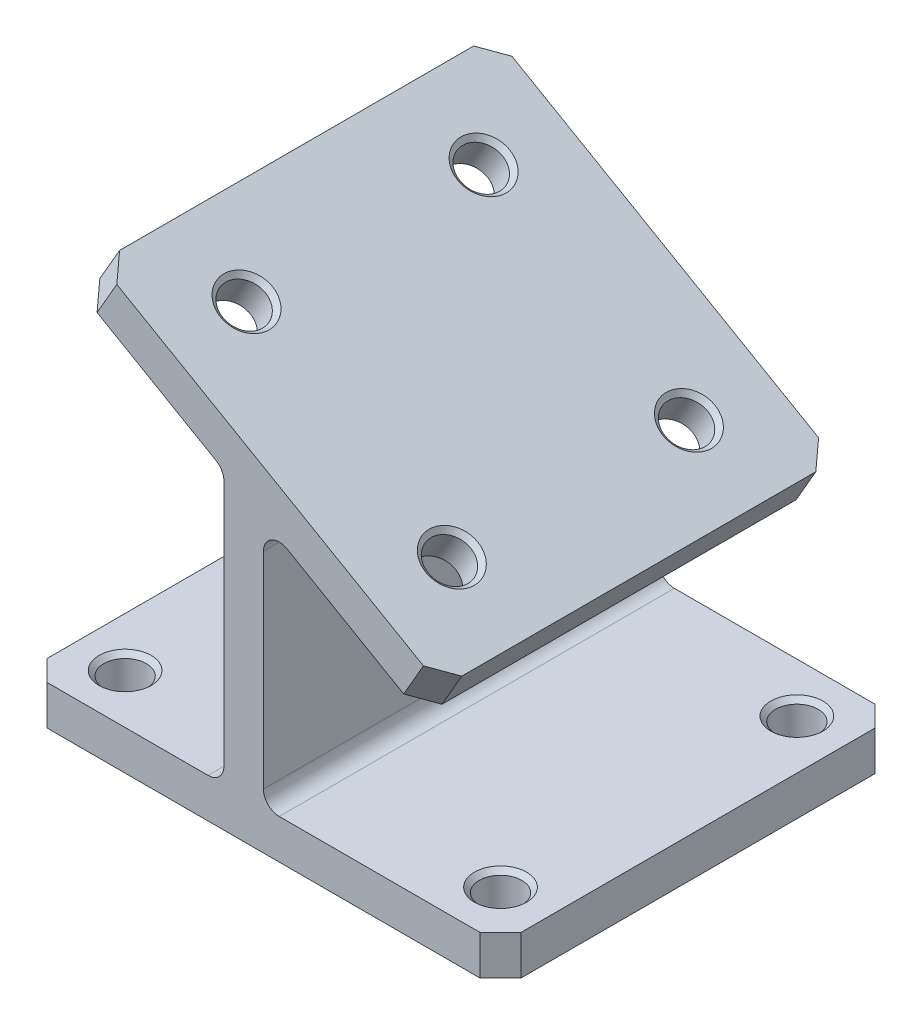
from build123d import *

# Parameters (mm, degrees)
BOSS_EXTRUDE1_DEPTH = 31.75
CHAMFER1_SIZE       = 3.302
CUT_EXTRUDE1_REACH  = 67.596
SKETCH2_R           = 3.429
CUT_EXTRUDE2_REACH  = 70.999
SKETCH3_R           = 3.429
CHAMFER2_SIZE       = 0.762


with BuildPart() as part:
    # Sketch1 → Boss-Extrude1 (new body, symmetric)
    with BuildSketch(Plane.XY):
        with BuildLine():
            Line((0, 2.54), (0, 42.264401363))
            ThreePointArc((0, 42.264401363), (-0.340295474, 43.534401363), (-1.27, 44.464105889))
            Line((-1.27, 44.464105889), (-23.24261314, 57.15))
            Line((-23.24261314, 57.15), (-20.06761314, 62.649261314))
            Line((-20.06761314, 62.649261314), (34.925, 30.899261314))
            Line((34.925, 30.899261314), (31.75, 25.4))
            Line((31.75, 25.4), (10.16, 37.864992312))
            ThreePointArc((10.16, 37.864992312), (7.62, 37.864992312), (6.35, 35.665287786))
            Line((6.35, 35.665287786), (6.35, 2.54))
            ThreePointArc((6.35, 2.54), (7.093948776, 0.743948776), (8.89, 0))
            Line((8.89, 0), (44.45, 0))
            Line((44.45, 0), (44.45, -6.35))
            Line((44.45, -6.35), (-31.75, -6.35))
            Line((-31.75, -6.35), (-31.75, 0))
            Line((-31.75, 0), (-2.54, 0))
            ThreePointArc((-2.54, 0), (-0.743948776, 0.743948776), (0, 2.54))
        make_face()
    extrude(amount=BOSS_EXTRUDE1_DEPTH, both=True)

    # Chamfer1
    chamfer1_edges = [part.edges().sort_by_distance(p)[0] for p in [
        (33.3375, 28.149630657, -31.75),
        (44.45, -3.175, -31.75),
        (-31.75, -3.175, -31.75),
        (-21.65511314, 59.899630657, -31.75),
        (-31.75, -3.175, 31.75),
        (44.45, -3.175, 31.75),
        (-21.65511314, 59.899630657, 31.75),
        (33.3375, 28.149630657, 31.75),
    ]]
    chamfer(chamfer1_edges, length=CHAMFER1_SIZE)

    # Sketch2 → Cut-Extrude1 (cut, up to next)
    with BuildSketch(Plane(origin=(22.111022628, 38.297414599, 0), x_dir=(0.866025404, -0.5, 0), z_dir=(0.5, 0.866025404, 0)), mode=Mode.PRIVATE) as cut_extrude1_sk1:
        with Locations((-36.00369343, 19.05)):
            Circle(SKETCH2_R)
    cut_extrude1_tool1 = extrude(cut_extrude1_sk1.sketch, amount=-CUT_EXTRUDE1_REACH, mode=Mode.PRIVATE) & part.part
    add(cut_extrude1_tool1.solids().sort_by_distance((-9.069091, 56.299261, -19.05))[0], mode=Mode.SUBTRACT)
    # Sketch2 → Cut-Extrude1 (cut, up to next)
    with BuildSketch(Plane(origin=(22.111022628, 38.297414599, 0), x_dir=(0.866025404, -0.5, 0), z_dir=(0.5, 0.866025404, 0)), mode=Mode.PRIVATE) as cut_extrude1_sk2:
        with Locations((2.09630657, 19.05)):
            Circle(SKETCH2_R)
    cut_extrude1_tool2 = extrude(cut_extrude1_sk2.sketch, amount=-CUT_EXTRUDE1_REACH, mode=Mode.PRIVATE) & part.part
    add(cut_extrude1_tool2.solids().sort_by_distance((23.926477, 37.249261, -19.05))[0], mode=Mode.SUBTRACT)
    # Sketch2 → Cut-Extrude1 (cut, up to next)
    with BuildSketch(Plane(origin=(22.111022628, 38.297414599, 0), x_dir=(0.866025404, -0.5, 0), z_dir=(0.5, 0.866025404, 0)), mode=Mode.PRIVATE) as cut_extrude1_sk3:
        with Locations((-36.00369343, -19.05)):
            Circle(SKETCH2_R)
    cut_extrude1_tool3 = extrude(cut_extrude1_sk3.sketch, amount=-CUT_EXTRUDE1_REACH, mode=Mode.PRIVATE) & part.part
    add(cut_extrude1_tool3.solids().sort_by_distance((-9.069091, 56.299261, 19.05))[0], mode=Mode.SUBTRACT)
    # Sketch2 → Cut-Extrude1 (cut, up to next)
    with BuildSketch(Plane(origin=(22.111022628, 38.297414599, 0), x_dir=(0.866025404, -0.5, 0), z_dir=(0.5, 0.866025404, 0)), mode=Mode.PRIVATE) as cut_extrude1_sk4:
        with Locations((2.09630657, -19.05)):
            Circle(SKETCH2_R)
    cut_extrude1_tool4 = extrude(cut_extrude1_sk4.sketch, amount=-CUT_EXTRUDE1_REACH, mode=Mode.PRIVATE) & part.part
    add(cut_extrude1_tool4.solids().sort_by_distance((23.926477, 37.249261, 19.05))[0], mode=Mode.SUBTRACT)

    # Sketch3 → Cut-Extrude2 (cut, up to next)
    with BuildSketch(Plane.XZ.offset(6.35), mode=Mode.PRIVATE) as cut_extrude2_sk1:
        with Locations((-23.8125, 23.8125)):
            Circle(SKETCH3_R)
    cut_extrude2_tool1 = extrude(cut_extrude2_sk1.sketch, amount=-CUT_EXTRUDE2_REACH, mode=Mode.PRIVATE) & part.part
    add(cut_extrude2_tool1.solids().sort_by_distance((-23.8125, -6.35, 23.8125))[0], mode=Mode.SUBTRACT)
    # Sketch3 → Cut-Extrude2 (cut, up to next)
    with BuildSketch(Plane.XZ.offset(6.35), mode=Mode.PRIVATE) as cut_extrude2_sk2:
        with Locations((36.5125, 23.8125)):
            Circle(SKETCH3_R)
    cut_extrude2_tool2 = extrude(cut_extrude2_sk2.sketch, amount=-CUT_EXTRUDE2_REACH, mode=Mode.PRIVATE) & part.part
    add(cut_extrude2_tool2.solids().sort_by_distance((36.5125, -6.35, 23.8125))[0], mode=Mode.SUBTRACT)
    # Sketch3 → Cut-Extrude2 (cut, up to next)
    with BuildSketch(Plane.XZ.offset(6.35), mode=Mode.PRIVATE) as cut_extrude2_sk3:
        with Locations((-23.8125, -23.8125)):
            Circle(SKETCH3_R)
    cut_extrude2_tool3 = extrude(cut_extrude2_sk3.sketch, amount=-CUT_EXTRUDE2_REACH, mode=Mode.PRIVATE) & part.part
    add(cut_extrude2_tool3.solids().sort_by_distance((-23.8125, -6.35, -23.8125))[0], mode=Mode.SUBTRACT)
    # Sketch3 → Cut-Extrude2 (cut, up to next)
    with BuildSketch(Plane.XZ.offset(6.35), mode=Mode.PRIVATE) as cut_extrude2_sk4:
        with Locations((36.5125, -23.8125)):
            Circle(SKETCH3_R)
    cut_extrude2_tool4 = extrude(cut_extrude2_sk4.sketch, amount=-CUT_EXTRUDE2_REACH, mode=Mode.PRIVATE) & part.part
    add(cut_extrude2_tool4.solids().sort_by_distance((36.5125, -6.35, -23.8125))[0], mode=Mode.SUBTRACT)

    # Chamfer2
    chamfer2_edges = [part.edges().sort_by_distance(p)[0] for p in [
        (17.781876262, 33.4645, -19.05),
        (20.956876262, 38.963761314, -19.05),
        (-12.038691622, 58.013761314, 19.05),
        (-15.213691622, 52.5145, 19.05),
        (17.781876262, 33.4645, 19.05),
        (20.956876262, 38.963761314, 19.05),
        (-12.038691622, 58.013761314, -19.05),
        (-15.213691622, 52.5145, -19.05),
        (33.0835, -6.35, 23.8125),
        (33.0835, 0, 23.8125),
        (-27.2415, -6.35, -23.8125),
        (-27.2415, 0, -23.8125),
        (33.0835, -6.35, -23.8125),
        (33.0835, 0, -23.8125),
        (-27.2415, -6.35, 23.8125),
        (-27.2415, 0, 23.8125),
    ]]
    chamfer(chamfer2_edges, length=CHAMFER2_SIZE)


solid = part.part
